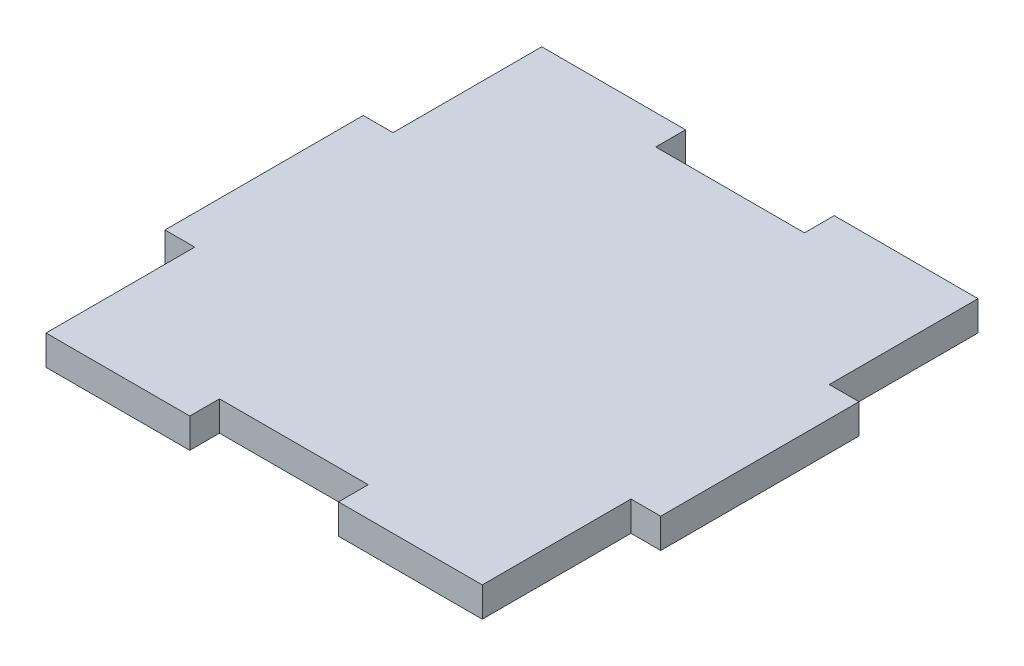
from build123d import *

# Parameters (mm, degrees)
EXTRUDE_1_DEPTH = 3


with BuildPart() as part:
    # 草图1 → 凸台-拉伸1 (new body)
    with BuildSketch(Plane(origin=(0, 0, 0), x_dir=(1, 0, 0), z_dir=(0, 1, 0))):
        Polygon((22, 25), (22, 10), (25, 10), (25, -10), (22, -10), (22, -25), (7.5, -25), (7.5, -22), (-7.5, -22), (-7.5, -25), (-22, -25), (-22, -10), (-25, -10), (-25, 10), (-22, 10), (-22, 25), (-7.5, 25), (-7.5, 22), (7.5, 22), (7.5, 25), align=None)
    extrude(amount=EXTRUDE_1_DEPTH)


solid = part.part
